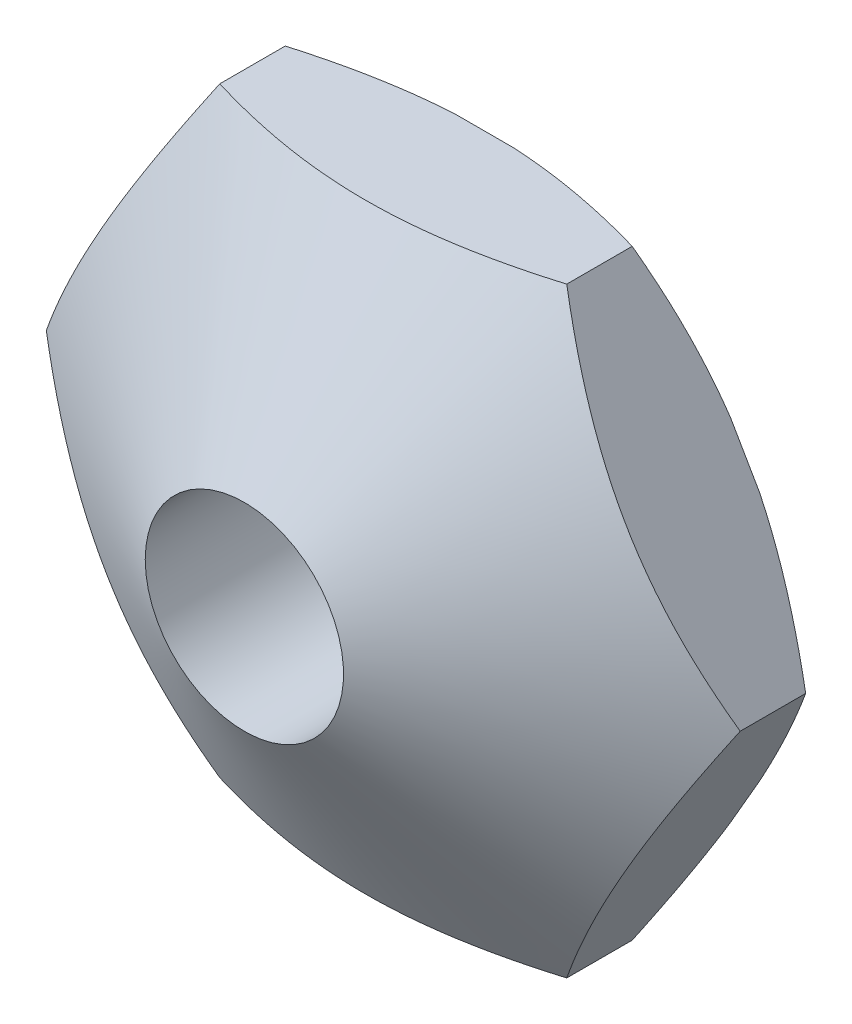
from build123d import *

# Parameters (mm, degrees)
BOSS_EXTRUDE1_DEPTH   = 4
M4X0_7_TAPPED_HOLE1_D = 3.3


with BuildPart() as part:
    # Sketch1 → Boss-Extrude1 (new body)
    with BuildSketch(Plane.XY):
        Polygon((-2.886751346, 5), (-5.773502692, 0), (-2.886751346, -5), (2.886751346, -5), (5.773502692, 0), (2.886751346, 5), align=None)
    extrude(amount=BOSS_EXTRUDE1_DEPTH)

    # M4x0.7 Tapped Hole1 (through all)
    with Locations(Plane(origin=(0, 0, 0), x_dir=(-1, 0, 0), z_dir=(0, 0, -1))):
        with Locations((0, 0)):
            Hole(M4X0_7_TAPPED_HOLE1_D / 2)

    # Sketch3 → Cut-Revolve3 (revolve, cut)
    with BuildSketch(Plane(origin=(0, 0, 0), x_dir=(1, 0, 0), z_dir=(0, 1, 0))):
        Polygon((6.057291813, -1.351831913), (1.65, -4), (6.057291813, -4), align=None)
    revolve(axis=Axis((0, 0, 4), (0, 0, 1)), mode=Mode.SUBTRACT)

    # Sketch5 → Cut-Revolve4 (revolve, cut)
    with BuildSketch(Plane(origin=(0, 0, 0), x_dir=(1, 0, 0), z_dir=(0, 1, 0))):
        Polygon((5.023502692, 0), (5.773502692, -0.433012702), (5.773502692, 0), align=None)
    revolve(axis=Axis((0, 0, 0), (0, 0, 1)), mode=Mode.SUBTRACT)


solid = part.part
